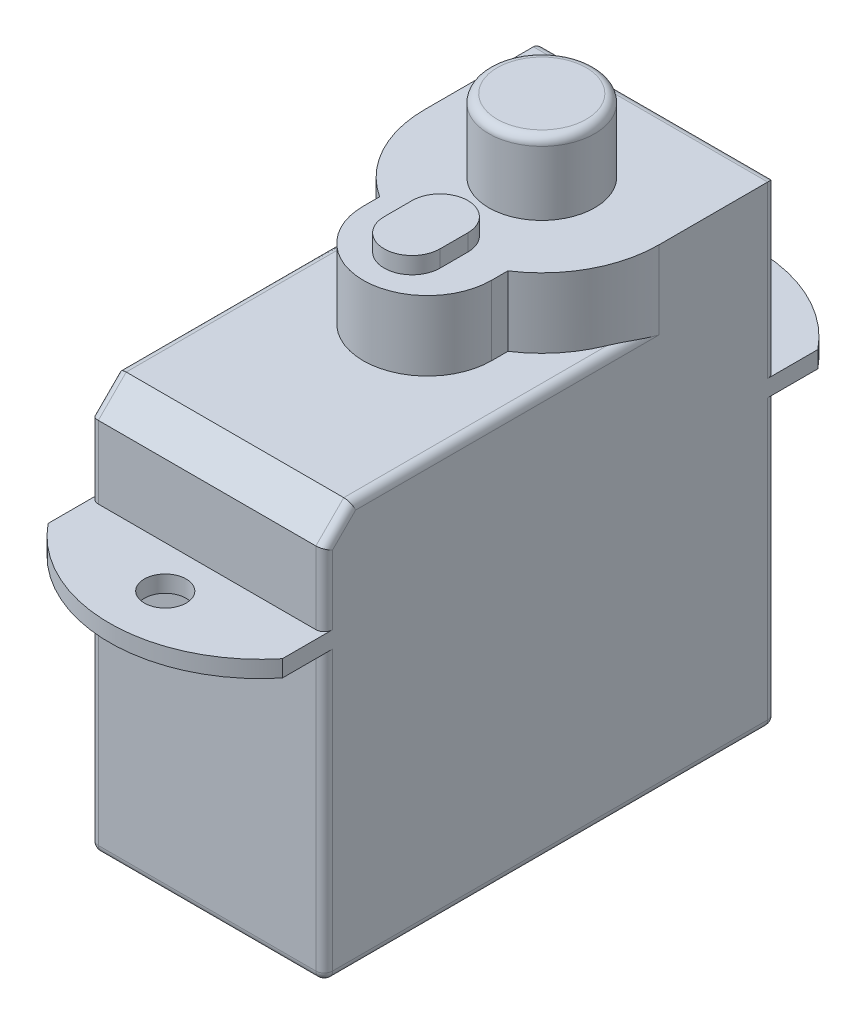
from build123d import *

# Parameters (mm, degrees)
SKETCH_1_W      = 8.4
SKETCH_1_H      = 16.2
EXTRUDE_1_DEPTH = 14.5
SKETCH_3_R      = 0.75
EXTRUDE_2_DEPTH = 0.6
EXTRUDE_3_DEPTH = 2.5
SKETCH_5_R      = 1.9
EXTRUDE_4_DEPTH = 2.6
EXTRUDE_5_DEPTH = 0.6
EXTRUDE_6_DEPTH = 0.5
CHAMFER_1_SIZE  = 1
FILLET_1_R      = 0.3


with BuildPart() as part:
    # 草图1 → 凸台-拉伸1 (new body)
    with BuildSketch(Plane(origin=(0, 0, 0), x_dir=(1, 0, 0), z_dir=(0, 1, 0))):
        with Locations((4.2, 8.1)):
            Rectangle(SKETCH_1_W, SKETCH_1_H)
    extrude(amount=EXTRUDE_1_DEPTH)

    # 草图3 → 凸台-拉伸2 (add)
    with BuildSketch(Plane(origin=(0, 10.3, 0), x_dir=(-1, 0, 0), z_dir=(0, -1, 0))):
        with BuildLine():
            Line((0, 16.2), (0, 17.7))
            ThreePointArc((0, 17.7), (-4.2, 19.7), (-8.4, 17.7))
            Line((-8.4, 17.7), (-8.4, 16.2))
            Line((-8.4, 16.2), (0, 16.2))
        make_face()
        with Locations((-4.2, 17.7)):
            Circle(SKETCH_3_R, mode=Mode.SUBTRACT)
        with BuildLine():
            Line((-8.4, 0), (0, 0))
            Line((0, 0), (0, -1.5))
            ThreePointArc((0, -1.5), (-4.2, -3.5), (-8.4, -1.5))
            Line((-8.4, -1.5), (-8.4, 0))
        make_face()
        with Locations((-4.2, -1.5)):
            Circle(SKETCH_3_R, mode=Mode.SUBTRACT)
    extrude(amount=-EXTRUDE_2_DEPTH)

    # 草图4 → 凸台-拉伸3 (add)
    with BuildSketch(Plane(origin=(0, 14.5, 0), x_dir=(1, 0, 0), z_dir=(0, 1, 0))):
        with BuildLine():
            Line((8.4, 12), (8.4, 16.2))
            Line((8.4, 16.2), (0, 16.2))
            Line((0, 16.2), (0, 12))
            ThreePointArc((0, 12), (0.50540936, 10.002501564), (1.9, 8.485743322))
            Line((1.9, 8.485743322), (1.9, 7.9))
            ThreePointArc((1.9, 7.9), (4.2, 5.6), (6.5, 7.9))
            Line((6.5, 7.9), (6.5, 8.485743322))
            ThreePointArc((6.5, 8.485743322), (7.89459064, 10.002501564), (8.4, 12))
        make_face()
    extrude(amount=EXTRUDE_3_DEPTH)

    # 草图5 → 凸台-拉伸4 (add)
    with BuildSketch(Plane(origin=(0, 17, 0), x_dir=(1, 0, 0), z_dir=(0, 1, 0))):
        with Locations((4.2, 12)):
            Circle(SKETCH_5_R)
    extrude(amount=EXTRUDE_4_DEPTH)

    # 草图6 → 凸台-拉伸5 (add)
    with BuildSketch(Plane(origin=(0, 17, 0), x_dir=(1, 0, 0), z_dir=(0, 1, 0))):
        with BuildLine():
            Line((5.2, 8.35), (5.2, 7.35))
            ThreePointArc((5.2, 7.35), (4.2, 6.35), (3.2, 7.35))
            Line((3.2, 7.35), (3.2, 8.35))
            ThreePointArc((3.2, 8.35), (4.2, 9.35), (5.2, 8.35))
        make_face()
    extrude(amount=EXTRUDE_5_DEPTH)

    # 草图7 → 凸台-拉伸6 (add)
    with BuildSketch(Plane(origin=(0, 0, -16.2), x_dir=(-1, 0, 0), z_dir=(0, 0, -1))):
        Polygon((-4.2, 4.3), (-6.1, 4.3), (-6.1, 0), (-2.3, 0), (-2.3, 4.3), align=None)
    extrude(amount=EXTRUDE_6_DEPTH)

    # 倒角1
    chamfer_1_edges = [part.edges().sort_by_distance(p)[0] for p in [
        (4.2, 14.5, 0),
    ]]
    chamfer(chamfer_1_edges, length=CHAMFER_1_SIZE)

    # 圆角1
    fillet_1_edges = [part.edges().sort_by_distance(p)[0] for p in [
        (1.15, 0, -16.2),
        (8.4, 14.5, -6.5),
        (8.4, 12.2, 0),
        (8.4, 14, -0.5),
        (0, 12.2, 0),
        (0, 14, -0.5),
        (0, 5.15, -16.2),
        (8.4, 5.15, -16.2),
        (8.4, 5.15, 0),
        (0, 5.15, 0),
        (0, 14.5, -6.5),
        (0, 0, -8.1),
        (4.2, 17, -16.2),
        (7.25, 0, -16.2),
        (8.4, 0, -8.1),
        (4.2, 0, 0),
        (2.3, 19.6, -12),
        (0, 13.95, -16.2),
        (8.4, 13.95, -16.2),
    ]]
    fillet(fillet_1_edges, radius=FILLET_1_R)


solid = part.part
